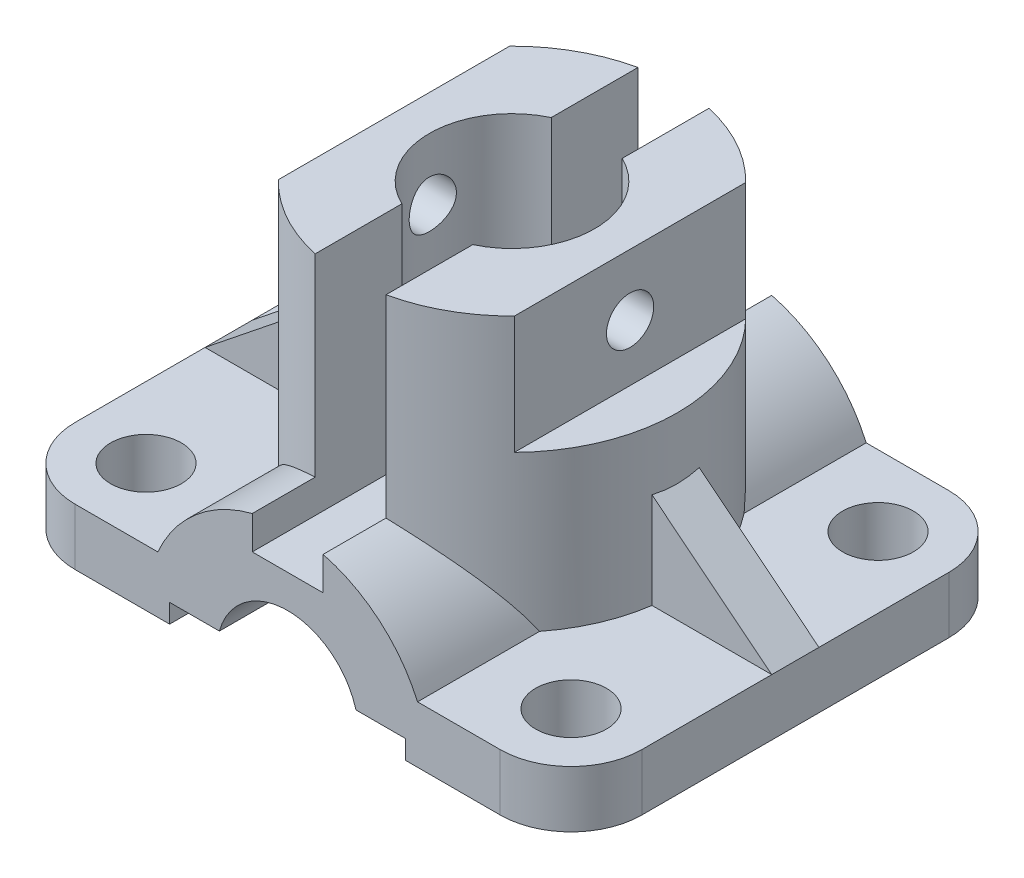
from build123d import *

# Parameters (mm, degrees)
EXTRUDE_1_DEPTH             = 12
EXTRUDE_2_DEPTH             = 95
SKETCH_3_W                  = 35
SKETCH_3_H                  = 70
RIB_1_REACH                 = 105.712
SKETCH_4_WALL_W             = 241.44030654
SKETCH_4_WALL_H             = 10
HOLE_WIZARD_15_0_15_1_D     = 15
PATTERN_LINEAR_2_COUNT      = 2
PATTERN_LINEAR_2_PITCH      = 90
PATTERN_LINEAR_2_COUNT_DIR2 = 2
PATTERN_LINEAR_2_PITCH_DIR2 = 65
CUT_EXTRUDE_1_DEPTH         = 133.382023073
SKETCH_9_R                  = 17.5
CUT_EXTRUDE_2_DEPTH         = 104.712342609
CUT_EXTRUDE_3_DEPTH         = 25
HOLE_WIZARD_10_0_10_2_D     = 10
SKETCH_22_W                 = 15
SKETCH_22_H                 = 48
CUT_EXTRUDE_6_DEPTH         = 133.382023073


with BuildPart() as part:
    # 草图1 → 凸台-拉伸1 (new body)
    with BuildSketch(Plane(origin=(0, 0, 0), x_dir=(1, 0, 0), z_dir=(0, 1, 0))):
        with BuildLine():
            Line((-45, 47.5), (45, 47.5))
            ThreePointArc((45, 47.5), (55.606601718, 43.106601718), (60, 32.5))
            Line((60, 32.5), (60, -32.5))
            ThreePointArc((60, -32.5), (55.606601718, -43.106601718), (45, -47.5))
            Line((45, -47.5), (-45, -47.5))
            ThreePointArc((-45, -47.5), (-55.606601718, -43.106601718), (-60, -32.5))
            Line((-60, -32.5), (-60, 32.5))
            ThreePointArc((-60, 32.5), (-55.606601718, 43.106601718), (-45, 47.5))
        make_face()
    extrude(amount=EXTRUDE_1_DEPTH)

    # 草图2 → 凸台-拉伸2 (add, through all)
    with BuildSketch(Plane.XY.offset(47.5)):
        with BuildLine():
            Line((-30, 0), (30, 0))
            ThreePointArc((30, 0), (0, 30), (-30, 0))
        make_face()
    extrude(amount=-EXTRUDE_2_DEPTH)

    # 草图3 → 旋转1 (revolve)
    with BuildSketch(Plane.XY, mode=Mode.PRIVATE) as revolve_1_sk:
        with Locations((17.5, 35)):
            Rectangle(SKETCH_3_W, SKETCH_3_H)
    revolve(revolve_1_sk.sketch.rotate(Axis((0, 0, 0), (0, 1, 0)), 90), axis=Axis((0, 0, 0), (0, 1, 0)))

    # 草图4 wall → 筋1 (add, up to next)
    with BuildSketch(Plane(origin=(-47.5, 22, 0), x_dir=(0.780868809443, 0.624695047554, 0), z_dir=(-0.624695047554, 0.780868809443, 0)), mode=Mode.PRIVATE) as rib_1_sk1:
        Rectangle(SKETCH_4_WALL_W, SKETCH_4_WALL_H)
    rib_1_tool1 = extrude(rib_1_sk1.sketch, amount=-RIB_1_REACH, mode=Mode.PRIVATE) - part.part
    rib_1 = rib_1_tool1.solids().sort_by_distance((-47.5, 22, 0))[0]
    add(rib_1)

    # 镜向1: 筋1 across plane
    add(rib_1.mirror(Plane(origin=(0, 0, 0), x_dir=(0, 0, 1), z_dir=(1, 0, 0))))

    # Ø15.0 (15) 直径孔1 (through all)
    with Locations(Plane(origin=(0, 12, 0), x_dir=(1, 0, 0), z_dir=(0, 1, 0))):
        with Locations((-45, -32.5)):
            hole_wizard_15_0_15_1 = Hole(HOLE_WIZARD_15_0_15_1_D / 2)

    # 阵列(线性)2: Hole Wizard 15.0 _15_ _1 2 × 2
    with Locations(*[(i * PATTERN_LINEAR_2_PITCH, 0, -j * PATTERN_LINEAR_2_PITCH_DIR2) for i in range(PATTERN_LINEAR_2_COUNT) for j in range(PATTERN_LINEAR_2_COUNT_DIR2) if (i, j) != (0, 0)]):
        add(hole_wizard_15_0_15_1, mode=Mode.SUBTRACT)

    # 草图7 → 切除-拉伸1 (cut, through all)
    with BuildSketch(Plane.XY.offset(47.5)):
        with BuildLine():
            Line((-25, 0), (25, 0))
            Line((25, 0), (25, 4))
            Line((25, 4), (14.456832295, 4))
            ThreePointArc((14.456832295, 4), (0, 15), (-14.456832295, 4))
            Line((-14.456832295, 4), (-25, 4))
            Line((-25, 4), (-25, 0))
        make_face()
    extrude(amount=-CUT_EXTRUDE_1_DEPTH, mode=Mode.SUBTRACT)

    # 草图9 → 切除-拉伸2 (cut, through all)
    with BuildSketch(Plane(origin=(0, 70, 0), x_dir=(1, 0, 0), z_dir=(0, 1, 0))):
        with Locations(Location((0, 0, 0), (0, 0, 270))):
            Circle(SKETCH_9_R)
    extrude(amount=-CUT_EXTRUDE_2_DEPTH, mode=Mode.SUBTRACT)

    # 草图10 → 切除-拉伸3 (cut)
    with BuildSketch(Plane(origin=(0, 70, 0), x_dir=(1, 0, 0), z_dir=(0, 1, 0))):
        with BuildLine():
            Line((-25, 24.494897428), (-25, -24.494897428))
            ThreePointArc((-25, -24.494897428), (-35, 0), (-25, 24.494897428))
        make_face()
        with BuildLine():
            Line((25, 24.494897428), (25, -24.494897428))
            ThreePointArc((25, -24.494897428), (35, 0), (25, 24.494897428))
        make_face()
    extrude(amount=-CUT_EXTRUDE_3_DEPTH, mode=Mode.SUBTRACT)

    # Ø10.0 (10) 直径孔2 (through all)
    with Locations(Plane.ZY.offset(25)):
        with Locations((0, 57)):
            Hole(HOLE_WIZARD_10_0_10_2_D / 2)

    # 草图22 → 切除-拉伸6 (cut, through all)
    with BuildSketch(Plane(origin=(0, 0, -47.5), x_dir=(-1, 0, 0), z_dir=(0, 0, -1))):
        with Locations((0, 46)):
            Rectangle(SKETCH_22_W, SKETCH_22_H)
    extrude(amount=-CUT_EXTRUDE_6_DEPTH, mode=Mode.SUBTRACT)


solid = part.part
